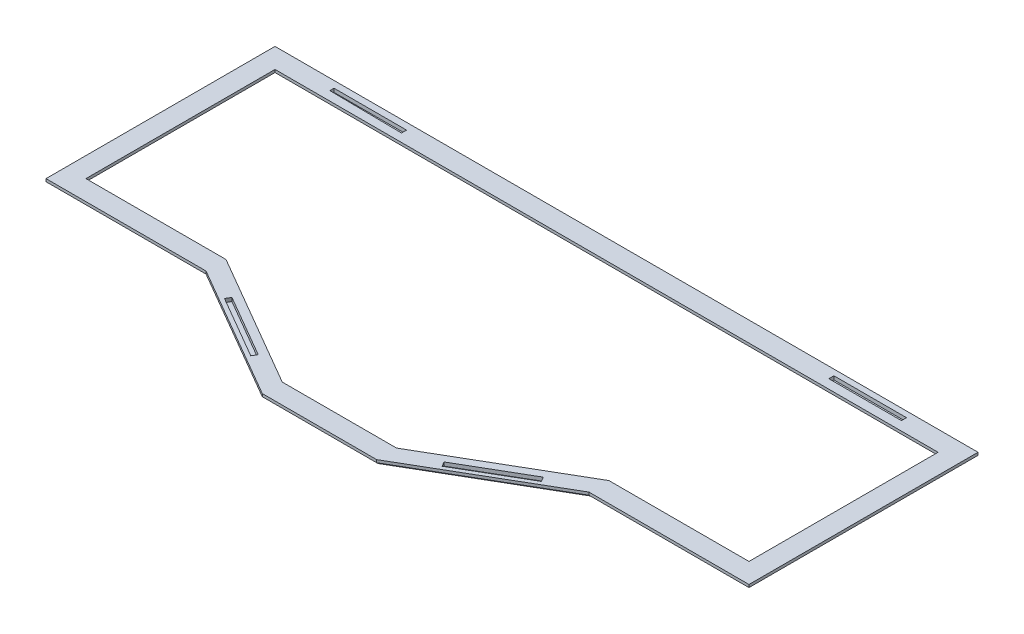
from build123d import *

# Parameters (mm, degrees)
SKETCH1_W           = 387.4
SKETCH1_H           = 169.4
BOSS_EXTRUDE1_DEPTH = 2.5
SKETCH3_W           = 40
SKETCH3_H           = 2.8
CUT_EXTRUDE2_DEPTH  = 2
CUT_EXTRUDE3_DEPTH  = 10
CUT_EXTRUDE4_DEPTH  = 3.5
CHAMFER1_SIZE       = 1
CHAMFER2_SIZE       = 1
CUT_EXTRUDE5_DEPTH  = 2


with BuildPart() as part:
    # Sketch1 → Boss-Extrude1 (new body)
    with BuildSketch(Plane(origin=(0, 0, 0), x_dir=(1, 0, 0), z_dir=(0, 1, 0))):
        Rectangle(SKETCH1_W, SKETCH1_H)
    extrude(amount=BOSS_EXTRUDE1_DEPTH)

    # Sketch3 → Cut-Extrude2 (cut)
    with BuildSketch(Plane(origin=(0, 2.5, 0), x_dir=(1, 0, 0), z_dir=(0, 1, 0))):
        with Locations((137.5, 80.1)):
            Rectangle(SKETCH3_W, SKETCH3_H)
        Polygon((-157.5, 81), (-157.5, 78.7), (-117.5, 78.2), (-117.5, 81), align=None)
    extrude(amount=-CUT_EXTRUDE2_DEPTH, mode=Mode.SUBTRACT)

    # Sketch4 → Cut-Extrude3 (cut)
    with BuildSketch(Plane.XZ):
        Polygon((31.499996994, 73.5), (105.5, 30.5), (182.7, 30.5), (182.7, -73.7), (-182.7, -73.7), (-182.7, 30.5), (-105.5, 30.5), (-31.499996994, 73.5), align=None)
    extrude(amount=-CUT_EXTRUDE3_DEPTH, mode=Mode.SUBTRACT)

    # Sketch7 → Cut-Extrude4 (cut, through all)
    with BuildSketch(Plane.XZ):
        Polygon((193.7, 41.5), (105.5, 41.5), (31.499996994, 84.5), (-31.499996994, 84.5), (-105.5, 41.5), (-193.7, 41.5), (-193.7, 84.7), (193.7, 84.7), align=None)
    extrude(amount=-CUT_EXTRUDE4_DEPTH, mode=Mode.SUBTRACT)

    # Chamfer1
    chamfer1_edges = [part.edges().sort_by_distance(p)[0] for p in [
        (-193.7, 0, -21.6),
        (0, 0, -84.7),
        (193.7, 0, -21.6),
        (-149.6, 0, 41.5),
        (-68.499998497, 0, 63),
        (0, 0, 84.5),
        (68.499998497, 0, 63),
        (149.6, 0, 41.5),
    ]]
    chamfer(chamfer1_edges, length=CHAMFER1_SIZE)

    # Chamfer2
    chamfer2_edges = [part.edges().sort_by_distance(p)[0] for p in [
        (0, 0, 73.5),
        (-68.499998497, 0, 52),
        (-144.1, 0, 30.5),
        (-182.7, 0, -21.6),
        (0, 0, -73.7),
        (182.7, 0, -21.6),
        (144.1, 0, 30.5),
        (68.499998497, 0, 52),
    ]]
    chamfer(chamfer2_edges, length=CHAMFER2_SIZE)

    # Sketch9 → Cut-Extrude5 (cut)
    with BuildSketch(Plane(origin=(0, 2.5, 0), x_dir=(1, 0, 0), z_dir=(0, 1, 0))):
        Polygon((-70.007252094, -59.593875696), (-52.714747454, -69.642222987), (-51.20749536, -67.048347291), (-85.79250464, -46.951652709), (-87.299756734, -49.545528405), align=None)
        Polygon((70.007252094, -59.593875696), (52.714747454, -69.642222987), (51.20749536, -67.048347291), (85.79250464, -46.951652709), (87.299756734, -49.545528405), align=None)
    extrude(amount=-CUT_EXTRUDE5_DEPTH, mode=Mode.SUBTRACT)


solid = part.part
